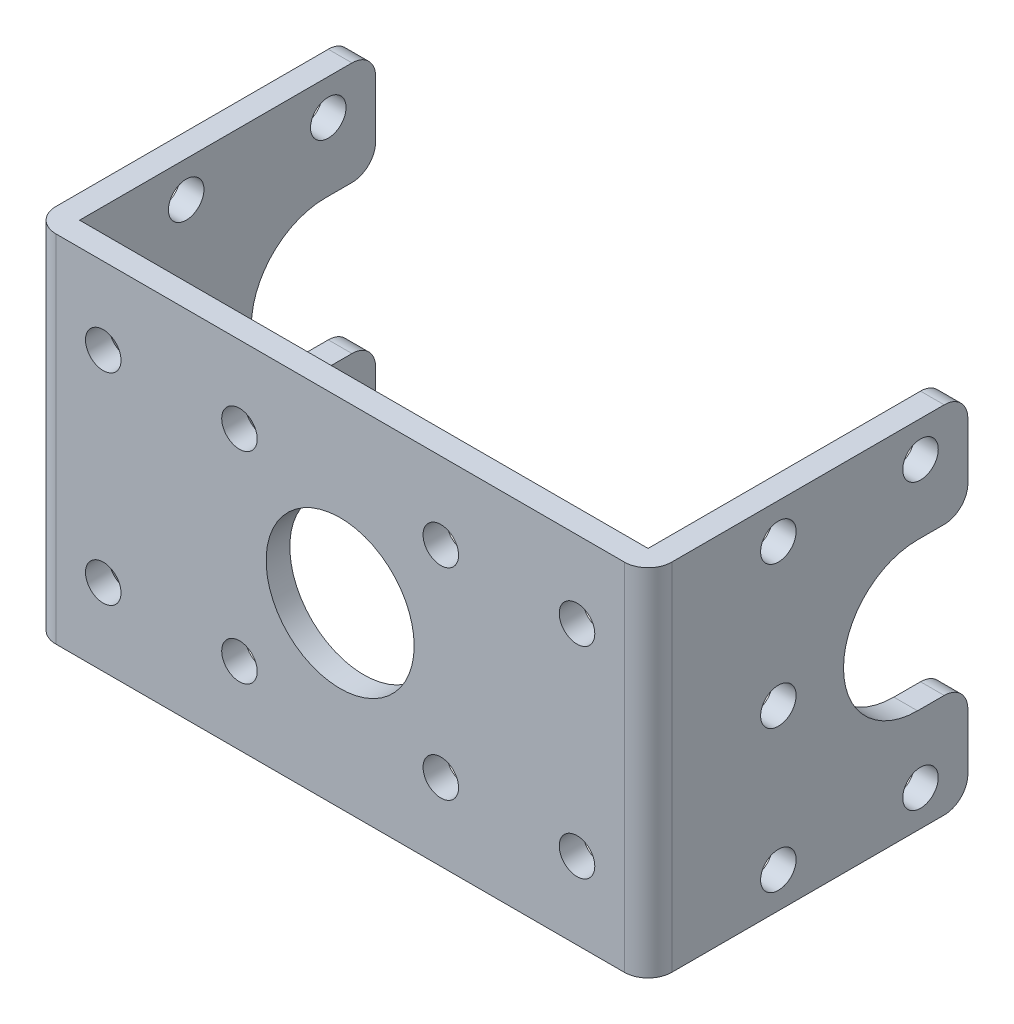
from build123d import *

# Parameters (mm, degrees)
BOSS_EXTRUDE1_DEPTH = 30
SKETCH2_R           = 1.5
CUT_EXTRUDE1_DEPTH  = 53
SKETCH3_R           = 6.25
SKETCH3_R_2         = 1.5
CUT_EXTRUDE2_DEPTH  = 30
FILLET1_R           = 2


with BuildPart() as part:
    # Sketch1 → Boss-Extrude1 (new body)
    with BuildSketch(Plane(origin=(0, 0, 0), x_dir=(1, 0, 0), z_dir=(0, 1, 0))):
        Polygon((24, 0), (24, -25), (-24, -25), (-24, 0), (-26, 0), (-26, -27), (26, -27), (26, 0), align=None)
    extrude(amount=BOSS_EXTRUDE1_DEPTH)

    # Sketch2 → Cut-Extrude1 (cut, through all)
    with BuildSketch(Plane(origin=(26, 0, 0), x_dir=(0, 0, -1), z_dir=(1, 0, 0))):
        with Locations((-4, 27)):
            Circle(SKETCH2_R)
        with Locations((-4, 3)):
            Circle(SKETCH2_R)
        with Locations((-16, 15)):
            Circle(SKETCH2_R)
        with Locations((-16, 27)):
            Circle(SKETCH2_R)
        with Locations((-16, 3)):
            Circle(SKETCH2_R)
        with BuildLine():
            Line((-4.25, 21.25), (0, 21.25))
            Line((0, 21.25), (0, 8.75))
            Line((0, 8.75), (-4.25, 8.75))
            ThreePointArc((-4.25, 8.75), (-10.5, 15), (-4.25, 21.25))
        make_face()
    extrude(amount=-CUT_EXTRUDE1_DEPTH, mode=Mode.SUBTRACT)

    # Sketch3 → Cut-Extrude2 (cut)
    with BuildSketch(Plane.XY.offset(27)):
        with Locations((0, 15)):
            Circle(SKETCH3_R)
        with Locations((20, 23.5)):
            Circle(SKETCH3_R_2)
        with Locations((20, 6.5)):
            Circle(SKETCH3_R_2)
        with Locations((8.5, 6.5)):
            Circle(SKETCH3_R_2)
        with Locations((8.5, 23.5)):
            Circle(SKETCH3_R_2)
        with Locations((-8.5, 6.5)):
            Circle(SKETCH3_R_2)
        with Locations((-20, 6.5)):
            Circle(SKETCH3_R_2)
        with Locations((-8.5, 23.5)):
            Circle(SKETCH3_R_2)
        with Locations((-20, 23.5)):
            Circle(SKETCH3_R_2)
    extrude(amount=-CUT_EXTRUDE2_DEPTH, mode=Mode.SUBTRACT)

    # Fillet1
    fillet1_edges = [part.edges().sort_by_distance(p)[0] for p in [
        (25, 0, 0),
        (26, 15, 27),
        (-26, 15, 27),
        (-25, 30, 0),
        (25, 30, 0),
        (25, 21.25, 0),
        (-25, 21.25, 0),
        (25, 8.75, 0),
        (-25, 8.75, 0),
        (-25, 0, 0),
    ]]
    fillet(fillet1_edges, radius=FILLET1_R)


solid = part.part
